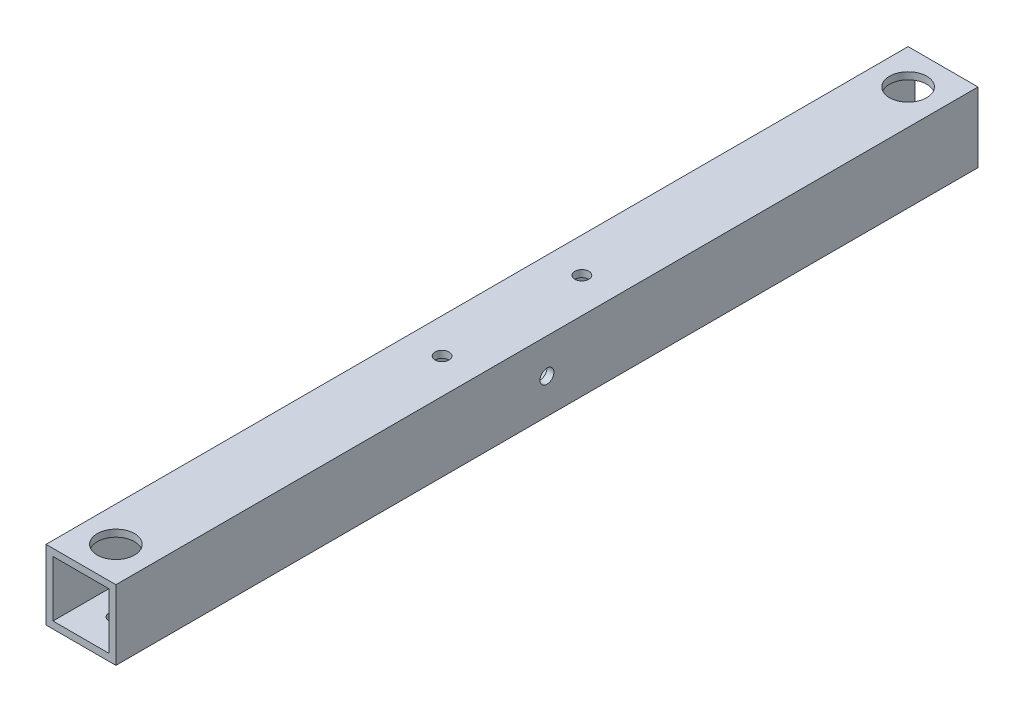
from build123d import *

# Parameters (mm, degrees)
SKETCH_1_W           = 15
SKETCH_1_H           = 15
SKETCH_1_W_2         = 12
SKETCH_1_H_2         = 12
EXTRUDE_2_DEPTH      = 185
SKETCH_2_R           = 4
CUT_EXTRUDE_1_DEPTH  = 10
SKETCH_3_R           = 4
CUT_EXTRUDE_2_DEPTH  = 10
SKETCH_4_R           = 1.5
CUT_EXTRUDE_3_DEPTH  = 10
SKETCH_5_R           = 1.5
CUT_EXTRUDE_4_DEPTH  = 10
SKETCH_6_R           = 1.5
CUT_EXTRUDE_5_DEPTH  = 10
SKETCH_8_R           = 1.5
CUT_EXTRUDE_6_DEPTH  = 10
CUT_EXTRUDE_7_DEPTH  = 10
SKETCH_10_R          = 4
CUT_EXTRUDE_8_DEPTH  = 10
SKETCH_11_R          = 1.5
CUT_EXTRUDE_9_DEPTH  = 10
SKETCH_12_R          = 4
CUT_EXTRUDE_10_DEPTH = 10


with BuildPart() as part:
    # ｽｹｯﾁ1 → ﾎﾞｽ - 押し出し2 (new body)
    with BuildSketch(Plane.XY):
        with Locations((0.489915859, 0.232626086)):
            Rectangle(SKETCH_1_W, SKETCH_1_H)
        with Locations((0.489915859, 0.232626086)):
            Rectangle(SKETCH_1_W_2, SKETCH_1_H_2, mode=Mode.SUBTRACT)
    extrude(amount=EXTRUDE_2_DEPTH)

    # ｽｹｯﾁ2 → ｶｯﾄ - 押し出し1 (cut)
    with BuildSketch(Plane(origin=(0, 7.732626086, 0), x_dir=(1, 0, 0), z_dir=(0, 1, 0))):
        with Locations((0.489915859, -7.5)):
            Circle(SKETCH_2_R)
    extrude(amount=-CUT_EXTRUDE_1_DEPTH, mode=Mode.SUBTRACT)

    # ｽｹｯﾁ3 → ｶｯﾄ - 押し出し2 (cut)
    with BuildSketch(Plane(origin=(0, 7.732626086, 0), x_dir=(1, 0, 0), z_dir=(0, 1, 0))):
        with Locations((0.489915859, -177.5)):
            Circle(SKETCH_3_R)
    extrude(amount=-CUT_EXTRUDE_2_DEPTH, mode=Mode.SUBTRACT)

    # ｽｹｯﾁ4 → ｶｯﾄ - 押し出し3 (cut)
    with BuildSketch(Plane.XZ.offset(7.267373914)):
        with Locations((0.489915859, 7.5)):
            Circle(SKETCH_4_R)
    extrude(amount=-CUT_EXTRUDE_3_DEPTH, mode=Mode.SUBTRACT)

    # ｽｹｯﾁ5 → ｶｯﾄ - 押し出し4 (cut)
    with BuildSketch(Plane.XZ.offset(7.267373914)):
        with Locations((0.489915859, 177.5)):
            Circle(SKETCH_5_R)
    extrude(amount=-CUT_EXTRUDE_4_DEPTH, mode=Mode.SUBTRACT)

    # ｽｹｯﾁ6 → ｶｯﾄ - 押し出し5 (cut)
    with BuildSketch(Plane(origin=(0, 7.732626086, 0), x_dir=(1, 0, 0), z_dir=(0, 1, 0))):
        with Locations((0.489915859, -77.5)):
            Circle(SKETCH_6_R)
    extrude(amount=-CUT_EXTRUDE_5_DEPTH, mode=Mode.SUBTRACT)

    # ｽｹｯﾁ8 → ｶｯﾄ - 押し出し6 (cut)
    with BuildSketch(Plane(origin=(0, 7.732626086, 0), x_dir=(1, 0, 0), z_dir=(0, 1, 0))):
        with Locations((0.489915859, -107.5)):
            Circle(SKETCH_8_R)
    extrude(amount=-CUT_EXTRUDE_6_DEPTH, mode=Mode.SUBTRACT)

    # ｽｹｯﾁ9 → ｶｯﾄ - 押し出し7 (cut)
    with BuildSketch(Plane.XZ.offset(7.267373914)):
        with BuildLine():
            ThreePointArc((4.489915859, 77.5), (3.318342984, 80.328427125), (0.489915859, 81.5))
            Line((0.489915859, 81.5), (0.489915859, 77.5))
            Line((0.489915859, 77.5), (4.489915859, 77.5))
        make_face()
        with BuildLine():
            Line((0.489915859, 77.5), (0.489915859, 81.5))
            ThreePointArc((0.489915859, 81.5), (-2.338511265, 74.671572875), (4.489915859, 77.5))
            Line((4.489915859, 77.5), (0.489915859, 77.5))
        make_face()
    extrude(amount=-CUT_EXTRUDE_7_DEPTH, mode=Mode.SUBTRACT)

    # ｽｹｯﾁ10 → ｶｯﾄ - 押し出し8 (cut)
    with BuildSketch(Plane.XZ.offset(7.267373914)):
        with Locations((0.489915859, 107.5)):
            Circle(SKETCH_10_R)
    extrude(amount=-CUT_EXTRUDE_8_DEPTH, mode=Mode.SUBTRACT)

    # ｽｹｯﾁ11 → ｶｯﾄ - 押し出し9 (cut)
    with BuildSketch(Plane(origin=(7.989915859, 0, 0), x_dir=(0, 0, -1), z_dir=(1, 0, 0))):
        with Locations((-92.5, 0.232626086)):
            Circle(SKETCH_11_R)
    extrude(amount=-CUT_EXTRUDE_9_DEPTH, mode=Mode.SUBTRACT)

    # ｽｹｯﾁ12 → ｶｯﾄ - 押し出し10 (cut)
    with BuildSketch(Plane.ZY.offset(7.010084141)):
        with Locations((92.5, 0.232626086)):
            Circle(SKETCH_12_R)
    extrude(amount=-CUT_EXTRUDE_10_DEPTH, mode=Mode.SUBTRACT)


solid = part.part
